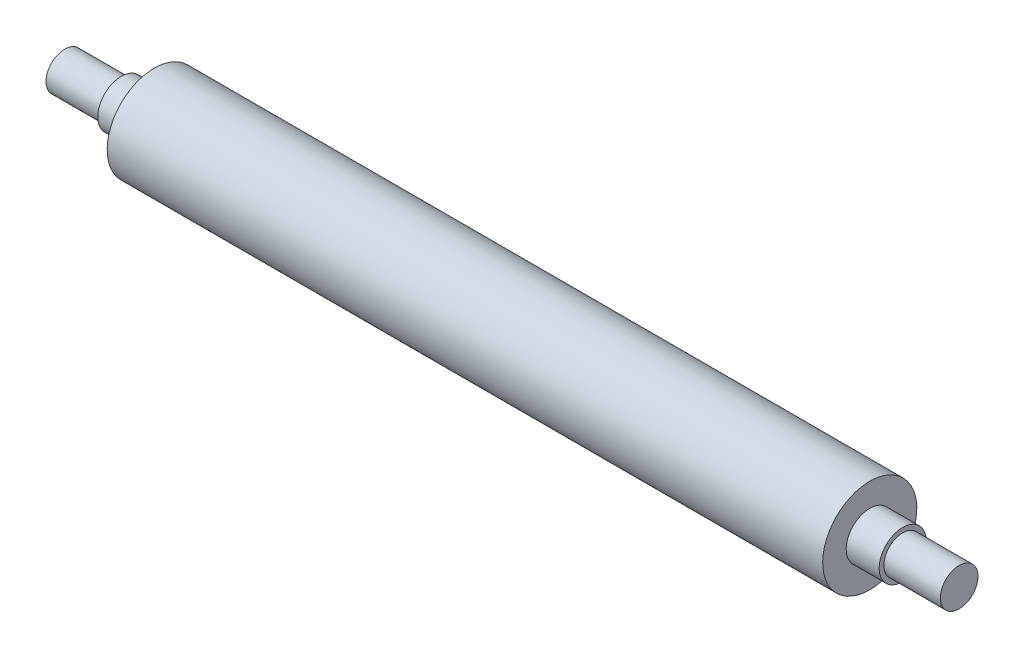
from build123d import *


with BuildPart() as part:
    # 草图1 → 旋转1 (revolve)
    with BuildSketch(Plane.XY):
        Polygon((-190, 25), (190, 25), (190, 12.5), (207.5, 12.5), (207.5, 10), (237.5, 10), (237.5, 0), (-237.5, 0), (-237.5, 10), (-207.5, 10), (-207.5, 12.5), (-190, 12.5), align=None)
    revolve(axis=Axis((-237.5, 0, 0), (1, 0, 0)))


solid = part.part
